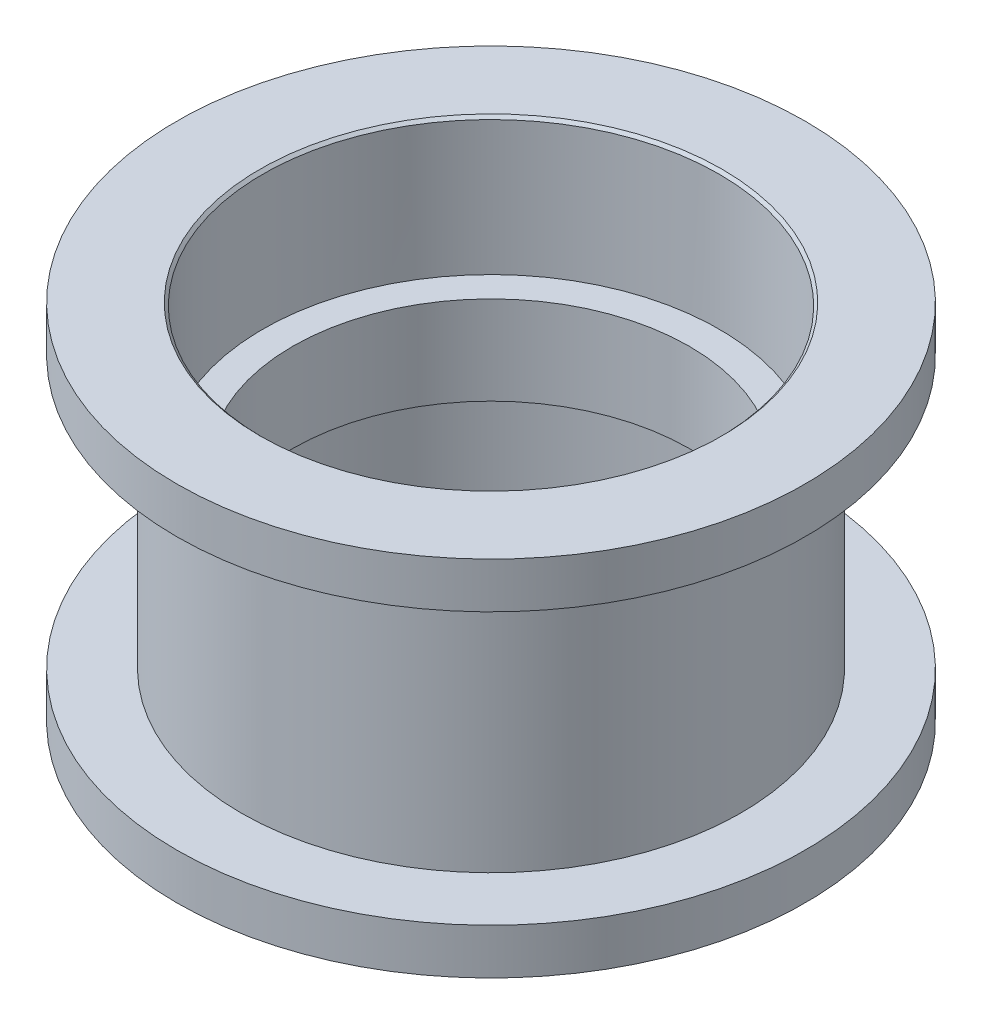
from build123d import *

# Parameters (mm, degrees)
CHAMFER1_SIZE = 0.1
CHAMFER2_SIZE = 0.1


with BuildPart() as part:
    # Sketch2 → Revolve1 (revolve)
    with BuildSketch(Plane.XY):
        Polygon((6.945, -1.55), (6.945, 1.55), (7.9875, 1.55), (7.9875, 6.35), (11, 6.35), (11, 4.75), (8.75, 4.75), (8.75, -4.75), (11, -4.75), (11, -6.35), (7.9875, -6.35), (7.9875, -1.55), align=None)
    revolve(axis=Axis((0, 30.498149714, 0), (0, -1, 0)))

    # Chamfer1
    chamfer1_edges = [part.edges().sort_by_distance(p)[0] for p in [
        (-7.9875, 6.35, 0),
    ]]
    chamfer(chamfer1_edges, length=CHAMFER1_SIZE)

    # Chamfer2
    chamfer2_edges = [part.edges().sort_by_distance(p)[0] for p in [
        (-7.9875, -6.35, 0),
    ]]
    chamfer(chamfer2_edges, length=CHAMFER2_SIZE)


solid = part.part
